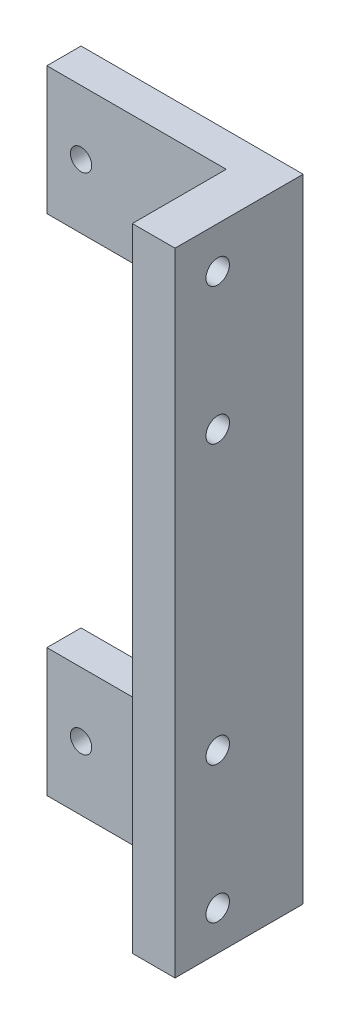
from build123d import *

# Parameters (mm, degrees)
SKETCH1_W             = 42
SKETCH1_H             = 30
BOSS_EXTRUDE1_DEPTH   = 8
BOSS_EXTRUDE1_2_DEPTH = 8
BOSS_EXTRUDE2_DEPTH   = 30
SKETCH2_R             = 2.5
CUT_EXTRUDE1_DEPTH    = 8
SKETCH3_R             = 2.75
CUT_EXTRUDE2_DEPTH    = 10


with BuildPart() as part:
    # Sketch1 → Boss-Extrude1 (new body)
    with BuildSketch(Plane.XY):
        with Locations((21, 133)):
            Rectangle(SKETCH1_W, SKETCH1_H)
    extrude(amount=BOSS_EXTRUDE1_DEPTH)



with BuildPart() as body_2:
    # Sketch1 → Boss-Extrude1 2 (new body)
    with BuildSketch(Plane.XY):
        with Locations((21, 15)):
            Rectangle(SKETCH1_W, SKETCH1_H)
    extrude(amount=BOSS_EXTRUDE1_2_DEPTH)


with BuildPart() as part_1:
    add(part.part)

    add(body_2.part)  # Boss-Extrude2 merges body 2
    # Sketch1_3 → Boss-Extrude2 (add)
    with BuildSketch(Plane.XY):
        Polygon((42, 30), (42, 0), (52, 0), (52, 148), (42, 148), (42, 118), align=None)
    extrude(amount=BOSS_EXTRUDE2_DEPTH)

    # Sketch2 → Cut-Extrude1 (cut)
    with BuildSketch(Plane.XY.offset(8)):
        with Locations((8, 133)):
            Circle(SKETCH2_R)
        with Locations((34, 133)):
            Circle(SKETCH2_R)
        with Locations((34, 15)):
            Circle(SKETCH2_R)
        with Locations((8, 15)):
            Circle(SKETCH2_R)
    extrude(amount=-CUT_EXTRUDE1_DEPTH, mode=Mode.SUBTRACT)

    # Sketch3 → Cut-Extrude2 (cut)
    with BuildSketch(Plane(origin=(52, 0, 0), x_dir=(0, 0, -1), z_dir=(1, 0, 0))):
        with Locations((-20, 138.3)):
            Circle(SKETCH3_R)
        with Locations((-20, 106.3)):
            Circle(SKETCH3_R)
        with Locations((-20, 41.2)):
            Circle(SKETCH3_R)
        with Locations((-20, 9.2)):
            Circle(SKETCH3_R)
    extrude(amount=-CUT_EXTRUDE2_DEPTH, mode=Mode.SUBTRACT)


solid = part_1.part
